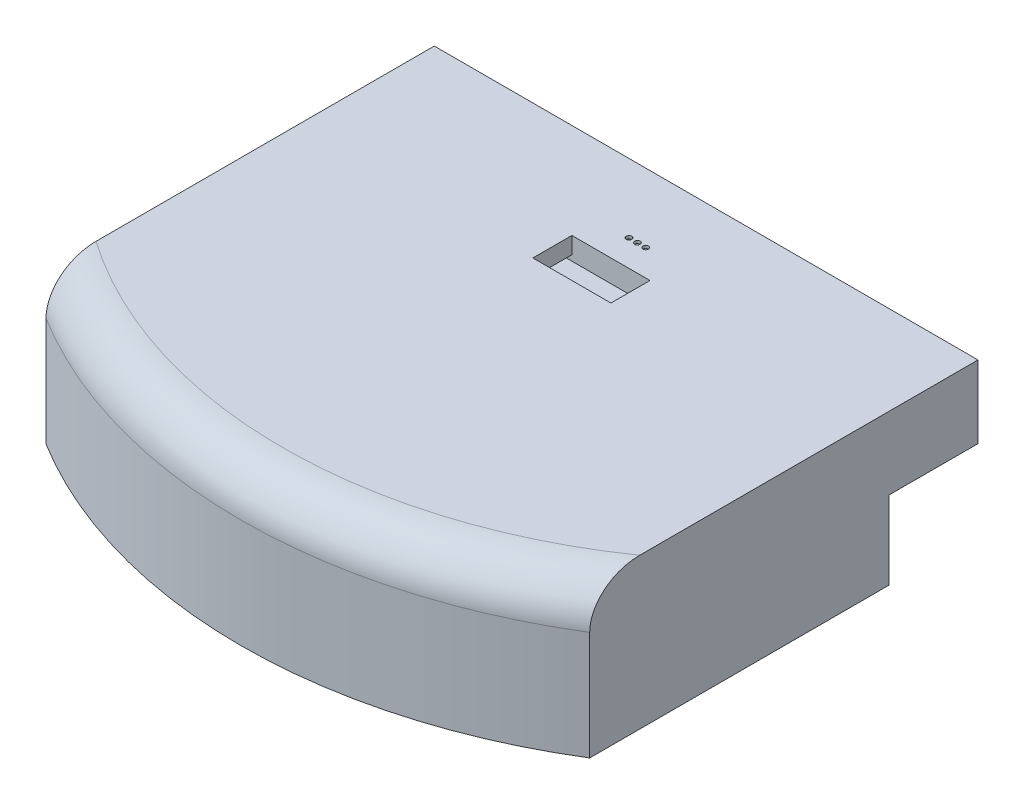
from build123d import *

# Parameters (mm, degrees)
BOSS_EXTRUDE1_DEPTH     = 54
FILLET1_R               = 15
SKETCH2_W               = 32
SKETCH2_H               = 28
CUT_EXTRUDE1_DEPTH      = 445
SKETCH3_W               = 13.8
SKETCH3_H               = 16.5
BOSS_EXTRUDE2_DEPTH     = 5.5
SKETCH4_W               = 13.8
SKETCH4_H               = 3.5
BOSS_EXTRUDE3_DEPTH     = 4
SKETCH5_R               = 1
CUT_EXTRUDE2_DEPTH      = 1
SKETCH6_W               = 28
SKETCH6_H               = 14
CUT_EXTRUDE3_DEPTH      = 8
SKETCH7_W               = 14
SKETCH7_H               = 2
CUT_EXTRUDE4_DEPTH      = 30
CUT_EXTRUDE4_DEPTH_BACK = 3


with BuildPart() as part:
    # Sketch1 → Boss-Extrude1 (new body)
    with BuildSketch(Plane(origin=(0, 0, 0), x_dir=(1, 0, 0), z_dir=(0, 1, 0))):
        with BuildLine():
            Line((-97.5, -18.771444772), (97.5, -18.771444772))
            Line((97.5, -18.771444772), (97.5, -158.031444772))
            ThreePointArc((97.5, -158.031444772), (0, -185.688415193), (-97.5, -158.031444772))
            Line((-97.5, -158.031444772), (-97.5, -18.771444772))
        make_face()
    extrude(amount=BOSS_EXTRUDE1_DEPTH)

    # Fillet1
    fillet1_edges = [part.edges().sort_by_distance(p)[0] for p in [
        (0, 54, 185.688415193),
    ]]
    fillet(fillet1_edges, radius=FILLET1_R)

    # Sketch2 → Cut-Extrude1 (cut)
    with BuildSketch(Plane.ZY.offset(97.5)):
        with Locations((34.771444772, 14)):
            Rectangle(SKETCH2_W, SKETCH2_H)
    extrude(amount=-CUT_EXTRUDE1_DEPTH, mode=Mode.SUBTRACT)

    # Sketch3 → Boss-Extrude2 (add)
    with BuildSketch(Plane.XZ):
        with Locations((0, 151.498415193)):
            Rectangle(SKETCH3_W, SKETCH3_H)
    extrude(amount=BOSS_EXTRUDE2_DEPTH)

    # Sketch4 → Boss-Extrude3 (add)
    with BuildSketch(Plane(origin=(0, 0, 143.248415193), x_dir=(-1, 0, 0), z_dir=(0, 0, -1))):
        with Locations((0, -3.75)):
            Rectangle(SKETCH4_W, SKETCH4_H)
    extrude(amount=BOSS_EXTRUDE3_DEPTH)

    # Sketch5 → Cut-Extrude2 (cut)
    with BuildSketch(Plane(origin=(0, 54, 0), x_dir=(1, 0, 0), z_dir=(0, 1, 0))):
        with Locations((0, -43.438827689)):
            Circle(SKETCH5_R)
        with Locations((3, -43.438827689)):
            Circle(SKETCH5_R)
        with Locations((-3, -43.438827689)):
            Circle(SKETCH5_R)
    extrude(amount=-CUT_EXTRUDE2_DEPTH, mode=Mode.SUBTRACT)

    # Sketch6 → Cut-Extrude3 (cut)
    with BuildSketch(Plane(origin=(0, 54, 0), x_dir=(1, 0, 0), z_dir=(0, 1, 0))):
        with Locations((0, -59.925549651)):
            Rectangle(SKETCH6_W, SKETCH6_H)
    extrude(amount=-CUT_EXTRUDE3_DEPTH, mode=Mode.SUBTRACT)

    # Sketch7 → Cut-Extrude4 (cut, two sides)
    with BuildSketch(Plane(origin=(-14, 0, 0), x_dir=(0, 0, -1), z_dir=(1, 0, 0))) as cut_extrude4_sk:
        with Locations((-59.925549651, 47)):
            Rectangle(SKETCH7_W, SKETCH7_H)
    extrude(amount=CUT_EXTRUDE4_DEPTH, mode=Mode.SUBTRACT)
    extrude(cut_extrude4_sk.sketch, amount=-CUT_EXTRUDE4_DEPTH_BACK, mode=Mode.SUBTRACT)


solid = part.part
